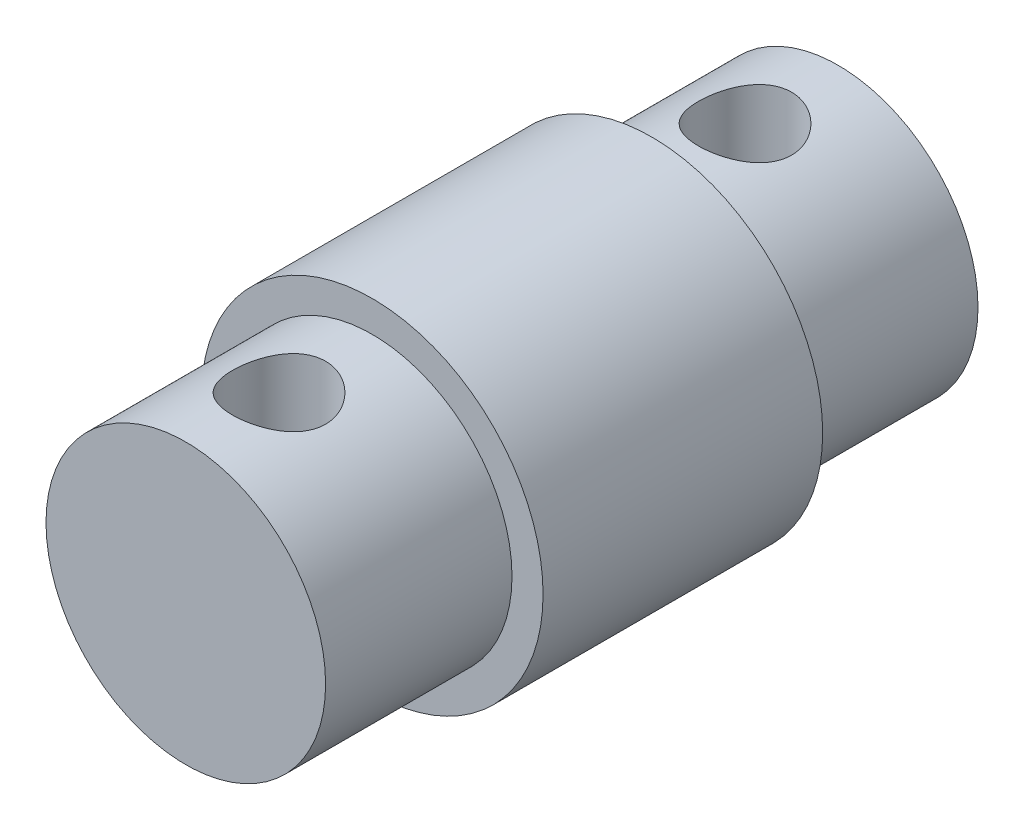
from build123d import *

# Parameters (mm, degrees)
SKETCH1_R               = 5.5
BOSS_EXTRUDE1_DEPTH     = 9
SKETCH2_R               = 4.5
BOSS_EXTRUDE2_DEPTH     = 6
SKETCH3_R               = 4.5
BOSS_EXTRUDE3_DEPTH     = 6
SKETCH4_R               = 1.5
CUT_EXTRUDE1_DEPTH      = 6.5
CUT_EXTRUDE1_DEPTH_BACK = 6.5


with BuildPart() as part:
    # Sketch1 → Boss-Extrude1 (new body)
    with BuildSketch(Plane.XY):
        Circle(SKETCH1_R)
    extrude(amount=BOSS_EXTRUDE1_DEPTH)

    # Sketch2 → Boss-Extrude2 (add)
    with BuildSketch(Plane.XY.offset(9)):
        Circle(SKETCH2_R)
    extrude(amount=BOSS_EXTRUDE2_DEPTH)

    # Sketch3 → Boss-Extrude3 (add)
    with BuildSketch(Plane(origin=(0, 0, 0), x_dir=(-1, 0, 0), z_dir=(0, 0, -1))):
        Circle(SKETCH3_R)
    extrude(amount=BOSS_EXTRUDE3_DEPTH)

    # Sketch4 → Cut-Extrude1 (cut, two sides)
    with BuildSketch(Plane(origin=(0, 0, 0), x_dir=(1, 0, 0), z_dir=(0, 1, 0))) as cut_extrude1_sk:
        with Locations((0, 3)):
            Circle(SKETCH4_R)
        with Locations((0, -12)):
            Circle(SKETCH4_R)
    extrude(amount=CUT_EXTRUDE1_DEPTH, mode=Mode.SUBTRACT)
    extrude(cut_extrude1_sk.sketch, amount=-CUT_EXTRUDE1_DEPTH_BACK, mode=Mode.SUBTRACT)


solid = part.part
